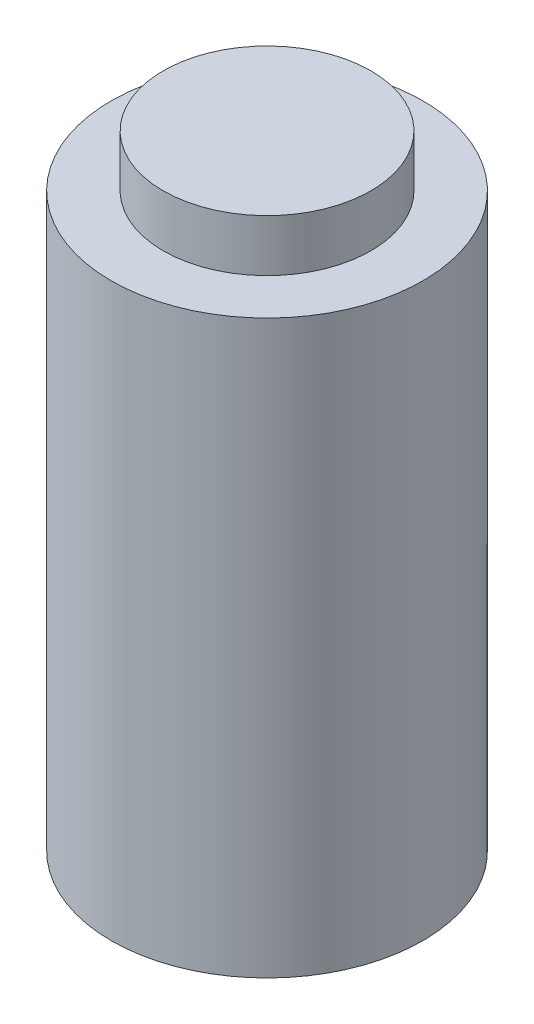
from build123d import *

# Parameters (mm, degrees)
SKETCH1_R           = 38.1
BOSS_EXTRUDE5_DEPTH = 139.7
SKETCH3_R           = 25.4
BOSS_EXTRUDE6_DEPTH = 12.7


with BuildPart() as part:
    # Sketch1 → Boss-Extrude5 (new body)
    with BuildSketch(Plane(origin=(0, 0, 0), x_dir=(1, 0, 0), z_dir=(0, 1, 0))):
        Circle(SKETCH1_R)
    extrude(amount=BOSS_EXTRUDE5_DEPTH)

    # Sketch3 → Boss-Extrude6 (add)
    with BuildSketch(Plane(origin=(0, 139.7, 0), x_dir=(1, 0, 0), z_dir=(0, 1, 0))):
        Circle(SKETCH3_R)
    extrude(amount=BOSS_EXTRUDE6_DEPTH)


solid = part.part
